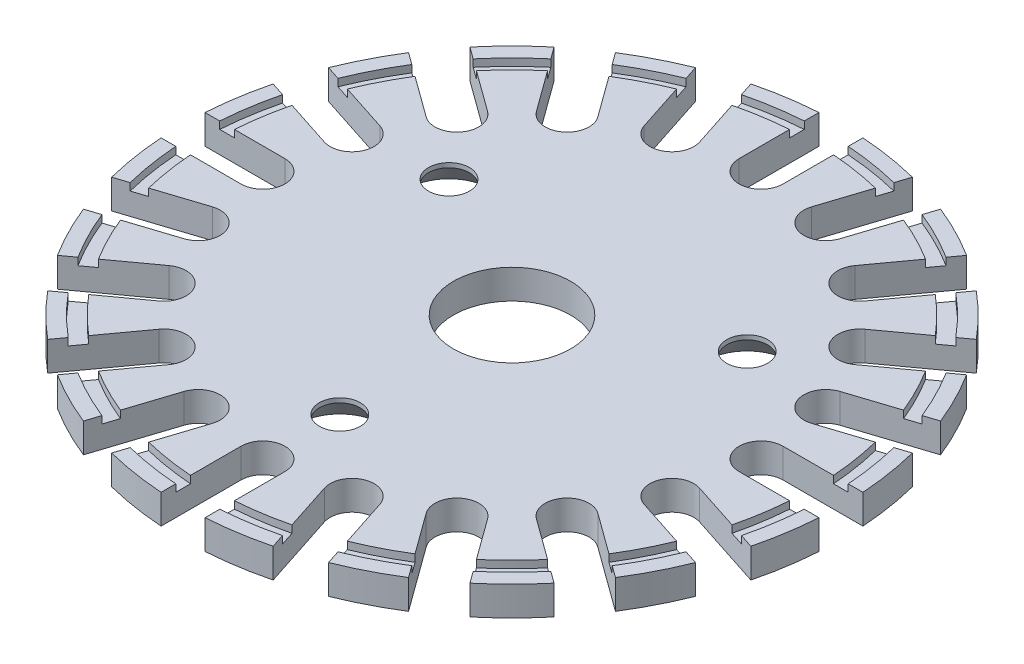
from build123d import *

# Parameters (mm, degrees)
SKETCH1_R                                         = 22.5
BOSS_EXTRUDE1_DEPTH                               = 2
CUT_EXTRUDE1_DEPTH                                = 2
CIRPATTERN1_COUNT                                 = 20
SKETCH3_R                                         = 21.5
SKETCH3_R_2                                       = 20.5
CUT_EXTRUDE2_DEPTH                                = 0.5
SKETCH4_R                                         = 4
CUT_EXTRUDE3_DEPTH                                = 3
CSK_FOR_3_FLAT_HEAD_SOCKET_CAP_SCREW1_D           = 2.794
CSK_FOR_3_FLAT_HEAD_SOCKET_CAP_SCREW1_DEPTH       = 5.5
CSK_FOR_3_FLAT_HEAD_SOCKET_CAP_SCREW1_CSINK_D     = 5.7404
CSK_FOR_3_FLAT_HEAD_SOCKET_CAP_SCREW1_CSINK_ANGLE = 82
CSK_FOR_3_FLAT_HEAD_SOCKET_CAP_SCREW1_TIP         = 0.839402285


with BuildPart() as part:
    # Sketch1 → Boss-Extrude1 (new body)
    with BuildSketch(Plane(origin=(0, 0, 0), x_dir=(1, 0, 0), z_dir=(0, 1, 0))):
        Circle(SKETCH1_R)
    extrude(amount=BOSS_EXTRUDE1_DEPTH)

    # Sketch2 → Cut-Extrude1 (cut)
    with BuildSketch(Plane(origin=(0, 2, 0), x_dir=(1, 0, 0), z_dir=(0, 1, 0))):
        with BuildLine():
            Line((1.5, 22.795822005), (1.5, 17))
            ThreePointArc((1.5, 17), (0, 15.5), (-1.5, 17))
            Line((-1.5, 17), (-1.5, 22.795822005))
            ThreePointArc((-1.5, 22.795822005), (0, 24.295822005), (1.5, 22.795822005))
        make_face()
    cut_extrude1 = extrude(amount=-CUT_EXTRUDE1_DEPTH, mode=Mode.SUBTRACT)

    # CirPattern1: Cut-Extrude1 ×20 about axis
    cirpattern1_axis = Axis((0, 0, 0), (0, 1, 0))
    for i in range(1, CIRPATTERN1_COUNT):
        add(cut_extrude1.rotate(cirpattern1_axis, i * 360 / CIRPATTERN1_COUNT), mode=Mode.SUBTRACT)

    # Sketch3 → Cut-Extrude2 (cut)
    with BuildSketch(Plane(origin=(0, 2, 0), x_dir=(1, 0, 0), z_dir=(0, 1, 0))):
        Circle(SKETCH3_R)
        Circle(SKETCH3_R_2, mode=Mode.SUBTRACT)
    extrude(amount=-CUT_EXTRUDE2_DEPTH, mode=Mode.SUBTRACT)

    # Sketch4 → Cut-Extrude3 (cut, through all)
    with BuildSketch(Plane(origin=(0, 2, 0), x_dir=(1, 0, 0), z_dir=(0, 1, 0))):
        Circle(SKETCH4_R)
    extrude(amount=-CUT_EXTRUDE3_DEPTH, mode=Mode.SUBTRACT)

    # CSK for #3 Flat Head Socket Cap Screw1
    with Locations(Plane(origin=(0, 0, 11.75), x_dir=(0, 0, -1), z_dir=(0, -1, 0))):
        with Locations((0, 0), (17.625, -10.175798494), (17.625, 10.175798494), (-17.809660155, -99.380305615)):
            CounterSinkHole(CSK_FOR_3_FLAT_HEAD_SOCKET_CAP_SCREW1_D / 2, CSK_FOR_3_FLAT_HEAD_SOCKET_CAP_SCREW1_CSINK_D / 2, depth=CSK_FOR_3_FLAT_HEAD_SOCKET_CAP_SCREW1_DEPTH, counter_sink_angle=CSK_FOR_3_FLAT_HEAD_SOCKET_CAP_SCREW1_CSINK_ANGLE)
            with Locations((0, 0, -(CSK_FOR_3_FLAT_HEAD_SOCKET_CAP_SCREW1_DEPTH + CSK_FOR_3_FLAT_HEAD_SOCKET_CAP_SCREW1_TIP / 2))):  # 118° drill point
                Cone(0, CSK_FOR_3_FLAT_HEAD_SOCKET_CAP_SCREW1_D / 2, CSK_FOR_3_FLAT_HEAD_SOCKET_CAP_SCREW1_TIP, mode=Mode.SUBTRACT)


solid = part.part
